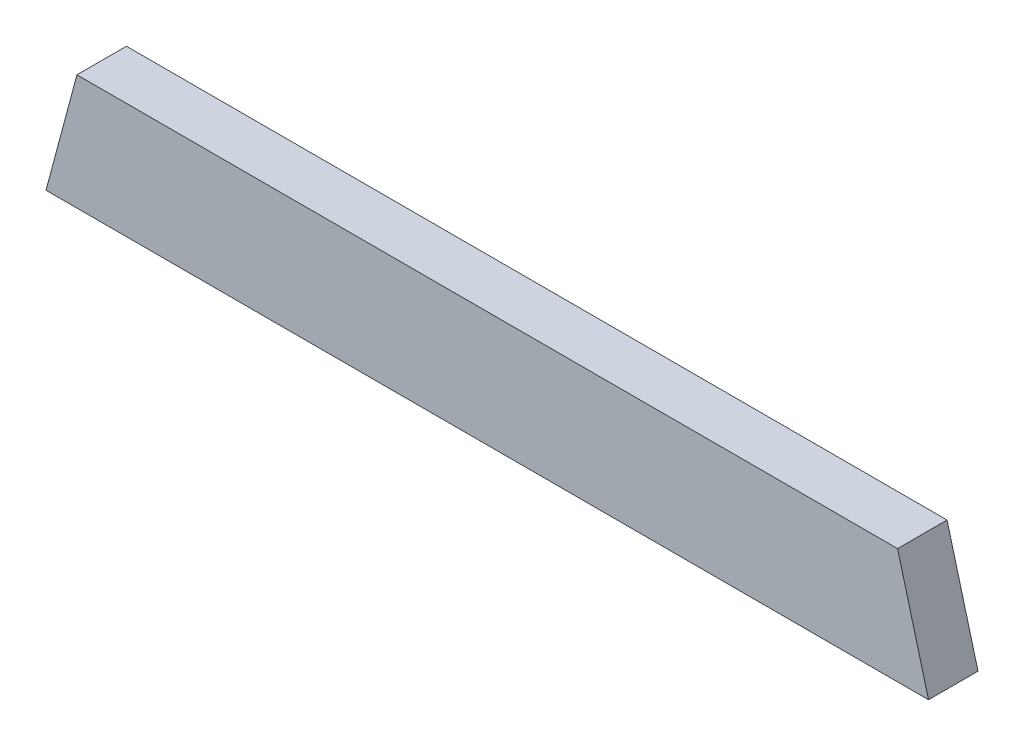
from build123d import *

# Parameters (mm, degrees)
BOSS_EXTRUDE1_DEPTH = 38.1


with BuildPart() as part:
    # Sketch1 → Boss-Extrude1 (new body)
    with BuildSketch(Plane.XY):
        Polygon((-315.9125, 88.9), (-339.733183207, 0), (339.733183207, 0), (315.9125, 88.9), align=None)
    extrude(amount=BOSS_EXTRUDE1_DEPTH)


solid = part.part
